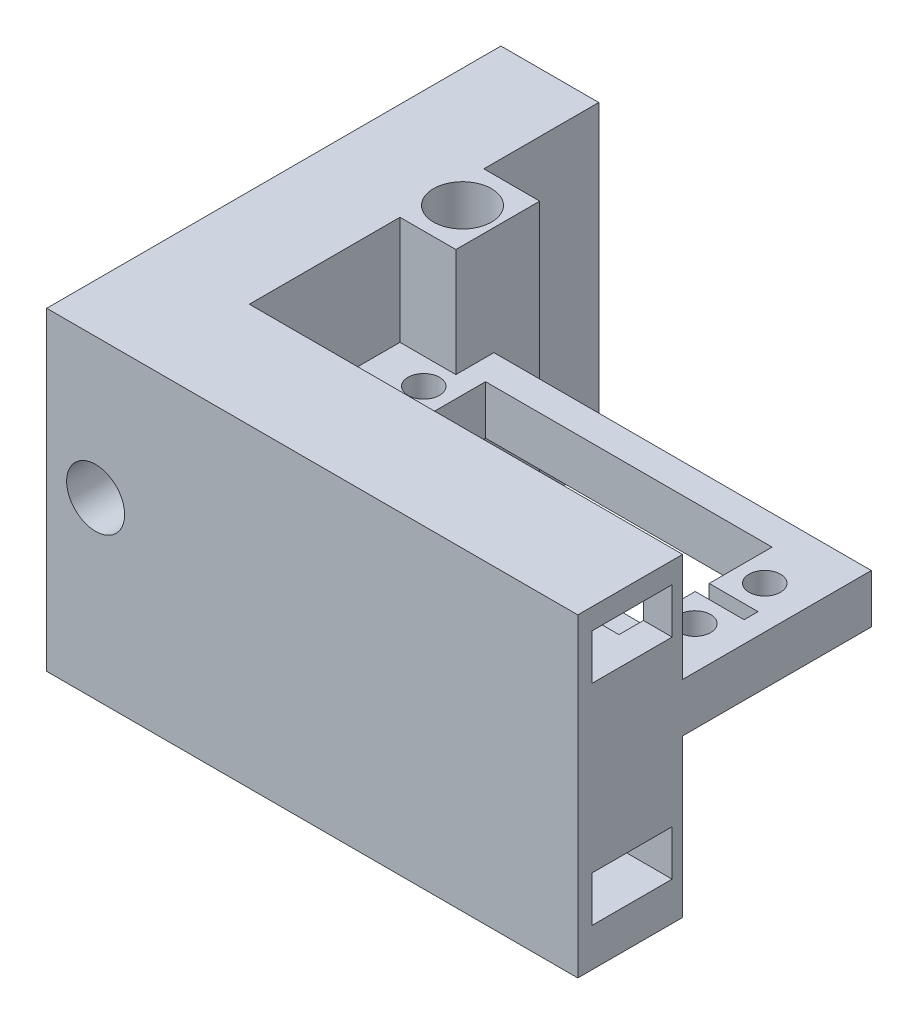
from build123d import *

# Parameters (mm, degrees)
SKETCH_1_W           = 45
SKETCH_1_H           = 45
EXTRUDE_1_DEPTH      = 100
SKETCH_2_OUTSIDE_W   = 125.706
SKETCH_2_OUTSIDE_H   = 70.706
SKETCH_2_OUTSIDE_W_2 = 62
SKETCH_2_OUTSIDE_H_2 = 8
CUT_EXTRUDE_1_DEPTH  = 30
SKETCH_3_W           = 41
SKETCH_3_H           = 20.3
CUT_EXTRUDE_2_DEPTH  = 30.5
SKETCH_5_W           = 11.5
SKETCH_5_H           = 6.5
CUT_EXTRUDE_3_DEPTH  = 101
SKETCH_7_R           = 2.25
SKETCH_7_W           = 7
SKETCH_7_H           = 2
CUT_EXTRUDE_5_DEPTH  = 10
SKETCH_9_W           = 62
SKETCH_9_H           = 8
CUT_EXTRUDE_7_DEPTH  = 3
SKETCH_10_W          = 15
SKETCH_10_H          = 45
CUT_EXTRUDE_8_DEPTH  = 24
SKETCH_13_W          = 14
SKETCH_13_H          = 45
EXTRUDE_3_DEPTH      = 50
SKETCH_14_R          = 4.15
CUT_EXTRUDE_9_DEPTH  = 66
SKETCH_15_W          = 12
SKETCH_15_H          = 45
EXTRUDE_4_DEPTH      = 8
SKETCH_17_R          = 4.15
CUT_EXTRUDE_11_DEPTH = 46
SKETCH_8_W           = 35
SKETCH_8_H           = 10
CUT_EXTRUDE_12_DEPTH = 5
CUT_EXTRUDE_14_DEPTH = 1


with BuildPart() as part:
    # 草图1 → 凸台-拉伸1 (new body)
    with BuildSketch(Plane(origin=(0, 0, 0), x_dir=(0, 0, -1), z_dir=(1, 0, 0))):
        with Locations((-1.383662758, -144.856597142)):
            Rectangle(SKETCH_1_W, SKETCH_1_H)
    extrude(amount=EXTRUDE_1_DEPTH)

    # 草图2 outside → 切除-拉伸1 (cut)
    with BuildSketch(Plane(origin=(0, 0, -21.116337242), x_dir=(-1, 0, 0), z_dir=(0, 0, -1))):
        with Locations((-50, -144.857)):
            Rectangle(SKETCH_2_OUTSIDE_W, SKETCH_2_OUTSIDE_H)
        with Locations((-45, -141.856597142)):
            Rectangle(SKETCH_2_OUTSIDE_W_2, SKETCH_2_OUTSIDE_H_2, mode=Mode.SUBTRACT)
    extrude(amount=-CUT_EXTRUDE_1_DEPTH, mode=Mode.SUBTRACT)

    # 草图3 → 切除-拉伸2 (cut, through all)
    with BuildSketch(Plane(origin=(0, -137.856597142, 0), x_dir=(1, 0, 0), z_dir=(0, 1, 0))):
        with Locations((45.5, 3.766337242)):
            Rectangle(SKETCH_3_W, SKETCH_3_H)
    extrude(amount=-CUT_EXTRUDE_2_DEPTH, mode=Mode.SUBTRACT)

    # 草图5 → 切除-拉伸3 (cut, through all)
    with BuildSketch(Plane.ZY):
        with Locations((16.133662758, -128.606597142)):
            Rectangle(SKETCH_5_W, SKETCH_5_H)
        with Locations((16.133662758, -158.606597142)):
            Rectangle(SKETCH_5_W, SKETCH_5_H)
    extrude(amount=-CUT_EXTRUDE_3_DEPTH, mode=Mode.SUBTRACT)

    # 草图7 → 切除-拉伸5 (cut)
    with BuildSketch(Plane.XZ.offset(145.856597142)):
        with Locations((21.15, -8.916337242)):
            Circle(SKETCH_7_R)
        with Locations((21.15, 1.083662758)):
            Circle(SKETCH_7_R)
        with Locations((69.95, -8.916337242)):
            Circle(SKETCH_7_R)
        with Locations((69.95, 1.083662758)):
            Circle(SKETCH_7_R)
        with Locations((21.5, -3.916337242)):
            Rectangle(SKETCH_7_W, SKETCH_7_H)
        with Locations((69.5, -3.916337242)):
            Rectangle(SKETCH_7_W, SKETCH_7_H)
    extrude(amount=-CUT_EXTRUDE_5_DEPTH, mode=Mode.SUBTRACT)

    # 草图9 → 切除-拉伸7 (cut)
    with BuildSketch(Plane(origin=(0, 0, -21.116337242), x_dir=(-1, 0, 0), z_dir=(0, 0, -1))):
        with Locations((-45, -141.856597142)):
            Rectangle(SKETCH_9_W, SKETCH_9_H)
    extrude(amount=-CUT_EXTRUDE_7_DEPTH, mode=Mode.SUBTRACT)

    # 草图10 → 切除-拉伸8 (cut)
    with BuildSketch(Plane(origin=(100, 0, 0), x_dir=(0, 0, -1), z_dir=(1, 0, 0))):
        with Locations((-16.383662758, -144.856597142)):
            Rectangle(SKETCH_10_W, SKETCH_10_H)
    extrude(amount=-CUT_EXTRUDE_8_DEPTH, mode=Mode.SUBTRACT)

    # 草图13 → 凸台-拉伸3 (add)
    with BuildSketch(Plane(origin=(0, 0, 8.883662758), x_dir=(-1, 0, 0), z_dir=(0, 0, -1))):
        with Locations((-7, -144.856597142)):
            Rectangle(SKETCH_13_W, SKETCH_13_H)
    extrude(amount=EXTRUDE_3_DEPTH)

    # 草图14 → 切除-拉伸9 (cut, through all)
    with BuildSketch(Plane(origin=(0, 0, -41.116337242), x_dir=(-1, 0, 0), z_dir=(0, 0, -1))):
        with Locations((-7, -142.356597142)):
            Circle(SKETCH_14_R)
    extrude(amount=-CUT_EXTRUDE_9_DEPTH, mode=Mode.SUBTRACT)

    # 草图15 → 凸台-拉伸4 (add)
    with BuildSketch(Plane(origin=(14, 0, 0), x_dir=(0, 0, -1), z_dir=(1, 0, 0))):
        with Locations((18.668900169, -144.856597142)):
            Rectangle(SKETCH_15_W, SKETCH_15_H)
    extrude(amount=EXTRUDE_4_DEPTH)

    # 草图17 → 切除-拉伸11 (cut, through all)
    with BuildSketch(Plane.XZ.offset(167.356597142)):
        with Locations((17, -18.616337242)):
            Circle(SKETCH_17_R)
    extrude(amount=-CUT_EXTRUDE_11_DEPTH, mode=Mode.SUBTRACT)

    # 草图8 → 切除-拉伸12 (cut)
    with BuildSketch(Plane(origin=(0, 0, 8.883662758), x_dir=(-1, 0, 0), z_dir=(0, 0, -1))):
        with Locations((-54.391773718, -128.856597142)):
            Rectangle(SKETCH_8_W, SKETCH_8_H)
    extrude(amount=-CUT_EXTRUDE_12_DEPTH, mode=Mode.SUBTRACT)

    # 草图18 → 切除-拉伸14 (cut)
    with BuildSketch(Plane.XZ.offset(145.856597142)):
        Polygon((76, 8.883662758), (22, 8.883662758), (14, 8.883662758), (14, -12.654298783), (22, -12.654298783), (22, -18.116337242), (76, -18.116337242), align=None)
    extrude(amount=-CUT_EXTRUDE_14_DEPTH, mode=Mode.SUBTRACT)


solid = part.part
